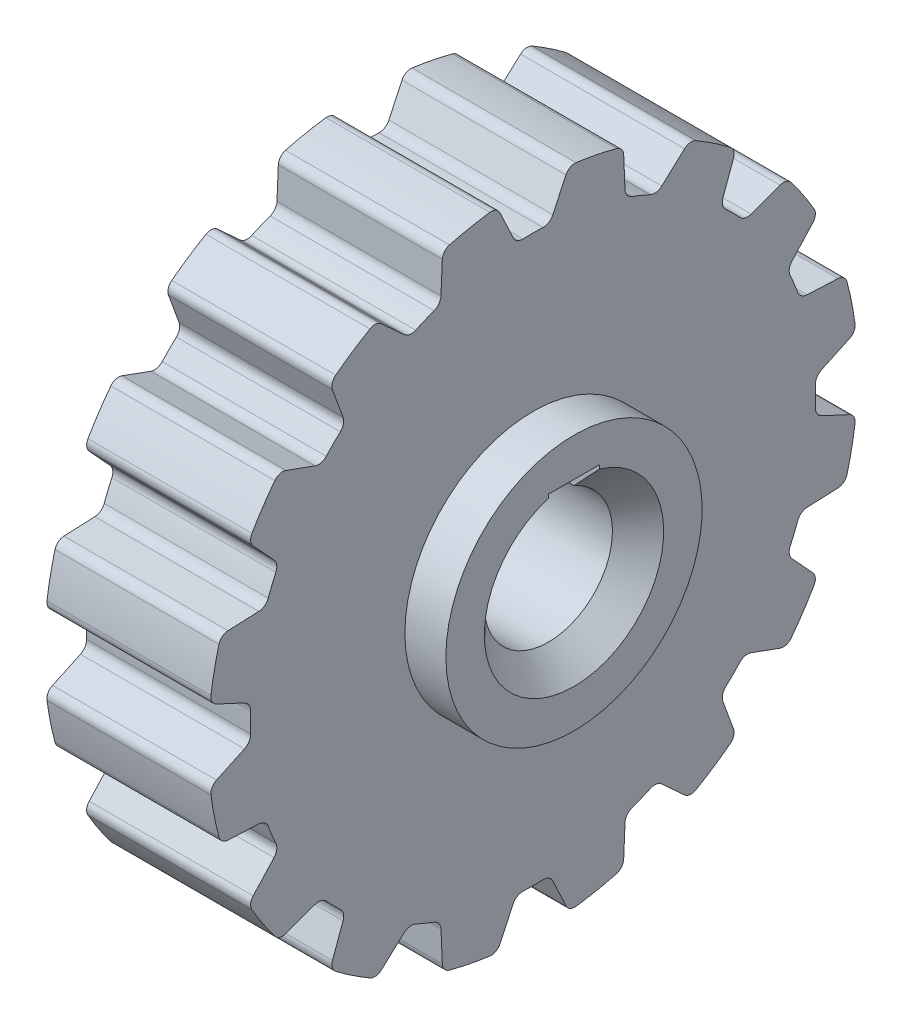
from build123d import *

# Parameters (mm, degrees)
CHAMFER_1_SIZE           = 1
SKETCH_4_W               = 2
SKETCH_4_H               = 1.208712153
CUT_EXTRUDE_1_DEPTH      = 20.637095559
CUT_EXTRUDE_2_REACH      = 21.637
PATTERN_CIRCULAR_3_COUNT = 16


with BuildPart() as part:
    # 草图1 → 旋转1 (revolve)
    with BuildSketch(Plane.XY):
        Polygon((0, 2.5), (0, 12.681), (6.4, 12.681), (6.4, 5), (8, 5), (8, 2.5), align=None)
    revolve(axis=Axis((0, 0, 0), (1, 0, 0)))

    # 倒角1
    chamfer_1_edges = [part.edges().sort_by_distance(p)[0] for p in [
        (8, -2.5, 0),
        (0, -2.5, 0),
    ]]
    chamfer(chamfer_1_edges, length=CHAMFER_1_SIZE)

    # 草图4 → 切除-拉伸1 (cut, through all)
    with BuildSketch(Plane.ZY):
        with Locations((0, 2.895643923)):
            Rectangle(SKETCH_4_W, SKETCH_4_H)
    extrude(amount=-CUT_EXTRUDE_1_DEPTH, mode=Mode.SUBTRACT)

    # 草图6 → 切除-拉伸2 (cut, up to next)
    with BuildSketch(Plane(origin=(0, 0, 0), x_dir=(0, 0, -1), z_dir=(1, 0, 0)), mode=Mode.PRIVATE) as cut_extrude_2_sk1:
        with BuildLine():
            Line((1.285723043, 12.353105336), (0.776264221, 11.260567368))
            ThreePointArc((0.776264221, 11.260567368), (0.618819992, 11.084207877), (0.390175975, 11.02409741))
            ThreePointArc((0.390175975, 11.02409741), (0, 11.031), (-0.390175975, 11.02409741))
            ThreePointArc((-0.390175975, 11.02409741), (-0.618819992, 11.084207877), (-0.776264221, 11.260567368))
            Line((-0.776264221, 11.260567368), (-1.285723043, 12.353105336))
            ThreePointArc((-1.285723043, 12.353105336), (-1.447679281, 12.525850138), (-1.680477339, 12.569158958))
            ThreePointArc((-1.680477339, 12.569158958), (-1.868612982, 12.542569375), (-2.056329114, 12.513163931))
            Line((-2.056329114, 12.513163931), (-2.671802841, 13.8330516))
            ThreePointArc((-2.671802841, 13.8330516), (0, 14.088713461), (2.671802841, 13.8330516))
            Line((2.671802841, 13.8330516), (2.056329114, 12.513163931))
            ThreePointArc((2.056329114, 12.513163931), (1.868612982, 12.542569375), (1.680477339, 12.569158958))
            ThreePointArc((1.680477339, 12.569158958), (1.447679281, 12.525850138), (1.285723043, 12.353105336))
        make_face()
    cut_extrude_2_tool1 = extrude(cut_extrude_2_sk1.sketch, amount=CUT_EXTRUDE_2_REACH, mode=Mode.PRIVATE) & part.part
    cut_extrude_2 = cut_extrude_2_tool1.solids().sort_by_distance((0, 12.873618, 0))[0]
    add(cut_extrude_2, mode=Mode.SUBTRACT)

    # 阵列(圆周)3: 切除-拉伸2 ×16 about axis
    pattern_circular_3_axis = Axis((-1.4, 0, 0), (1, 0, 0))
    for i in range(1, PATTERN_CIRCULAR_3_COUNT):
        add(cut_extrude_2.rotate(pattern_circular_3_axis, i * 360 / PATTERN_CIRCULAR_3_COUNT), mode=Mode.SUBTRACT)


solid = part.part
